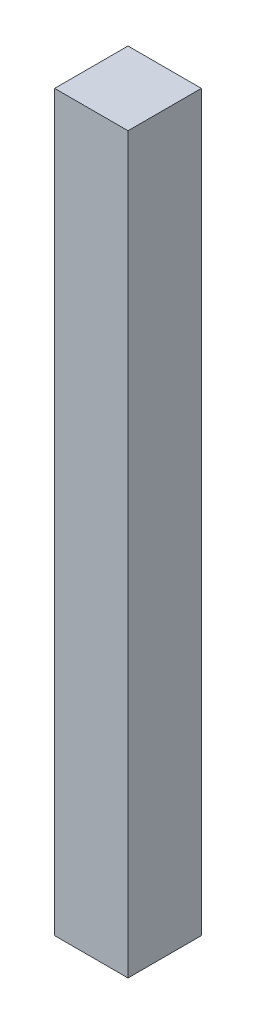
from build123d import *

# Parameters (mm, degrees)
SKIZZE1_W                       = 20
SKIZZE1_H                       = 20
AUFSATZ_LINEAR_AUSTRAGEN1_DEPTH = 200


with BuildPart() as part:
    # Skizze1 → Aufsatz-Linear austragen1 (new body)
    with BuildSketch(Plane(origin=(0, 0, 0), x_dir=(1, 0, 0), z_dir=(0, 1, 0))):
        with Locations((10, -10)):
            Rectangle(SKIZZE1_W, SKIZZE1_H)
    extrude(amount=AUFSATZ_LINEAR_AUSTRAGEN1_DEPTH)


solid = part.part
